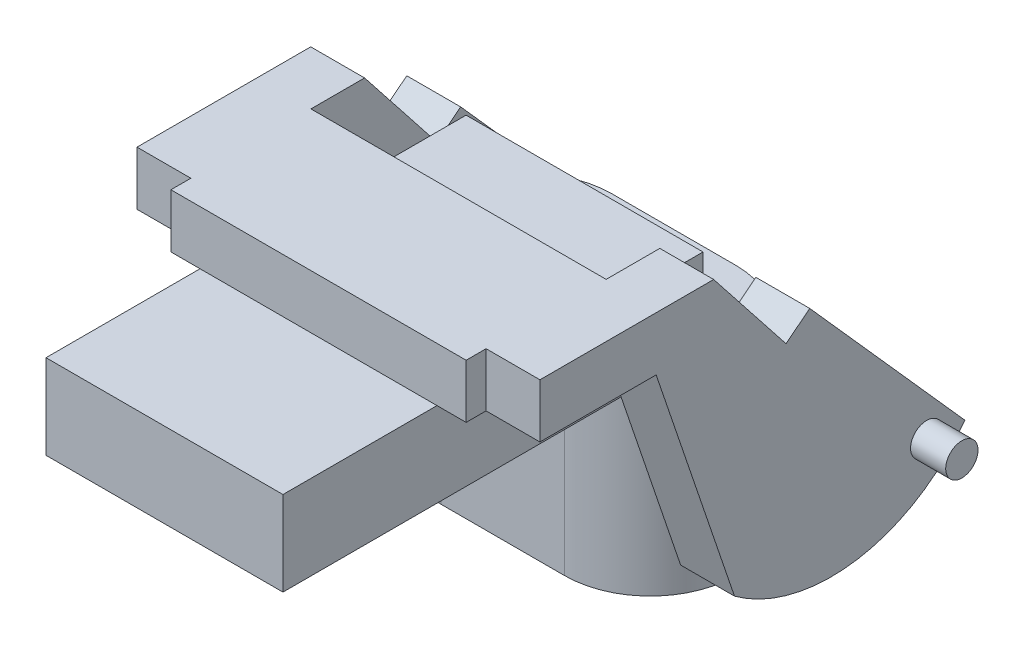
from build123d import *

# Parameters (mm, degrees)
SZKIC1_W                     = 44
SZKIC1_H                     = 78
DODANIE_WYCI_GNI_CIE1_DEPTH  = 15.7
SZKIC2_W                     = 54.82
SZKIC2_H                     = 26
DODANIE_WYCI_GNI_CIE2_DEPTH  = 10
DODANIE_WYCI_GNI_CIE3_DEPTH  = 1
SZKIC6_R                     = 10.4
SZKIC6_R_2                   = 4
DODANIE_WYCI_GNI_CIE4_DEPTH  = 33
SZKIC7_R                     = 10.5
DODANIE_WYCI_GNI_CIE5_DEPTH  = 33
DODANIE_WYCI_GNI_CIE6_DEPTH  = 33
DODANIE_WYCI_GNI_CIE22_DEPTH = 10
SZKIC15_R                    = 3
DODANIE_WYCI_GNI_CIE23_DEPTH = 6.525


with BuildPart() as part:
    # Szkic1 → Dodanie-wyciągnięcie1 (new body)
    with BuildSketch(Plane(origin=(0, 0, 0), x_dir=(1, 0, 0), z_dir=(0, 1, 0))):
        with Locations((-44.05199022, 33.7842123)):
            Rectangle(SZKIC1_W, SZKIC1_H)
    extrude(amount=DODANIE_WYCI_GNI_CIE1_DEPTH)

    # Szkic2 → Dodanie-wyciągnięcie2 (add)
    with BuildSketch(Plane(origin=(0, 15.7, 0), x_dir=(1, 0, 0), z_dir=(0, 1, 0))):
        with Locations((-44.05199022, 36.3842123)):
            Rectangle(SZKIC2_W, SZKIC2_H)
    extrude(amount=DODANIE_WYCI_GNI_CIE2_DEPTH)

    # Szkic3 → Dodanie-wyciągnięcie3 (add)
    with BuildSketch(Plane.XZ):
        with BuildLine():
            Line((-32.55199022, -89.3842123), (-55.55199022, -89.3842123))
            ThreePointArc((-55.55199022, -89.3842123), (-71.45199022, -73.4842123), (-55.55199022, -57.5842123))
            Line((-55.55199022, -57.5842123), (-32.55199022, -57.5842123))
            ThreePointArc((-32.55199022, -57.5842123), (-16.65199022, -73.4842123), (-32.55199022, -89.3842123))
        make_face()
    extrude(amount=DODANIE_WYCI_GNI_CIE3_DEPTH)

    # Szkic6 → Dodanie-wyciągnięcie4 (add)
    with BuildSketch(Plane(origin=(0, -1, 0), x_dir=(-1, 0, 0), z_dir=(0, -1, 0))):
        with Locations((32.55199022, 73.4842123)):
            Circle(SZKIC6_R)
        with Locations((32.55199022, 73.4842123)):
            Circle(SZKIC6_R_2, mode=Mode.SUBTRACT)
        with Locations((55.55199022, 73.4842123)):
            Circle(SZKIC6_R)
        with Locations((55.55199022, 73.4842123)):
            Circle(SZKIC6_R_2, mode=Mode.SUBTRACT)
    extrude(amount=DODANIE_WYCI_GNI_CIE4_DEPTH)

    # Szkic7 → Dodanie-wyciągnięcie5 (add)
    with BuildSketch(Plane(origin=(0, -1, 0), x_dir=(-1, 0, 0), z_dir=(0, -1, 0))):
        with BuildLine():
            Line((55.55199022, 57.9842123), (32.55199022, 57.9842123))
            ThreePointArc((32.55199022, 57.9842123), (17.05199022, 73.4842123), (32.55199022, 88.9842123))
            Line((32.55199022, 88.9842123), (55.55199022, 88.9842123))
            ThreePointArc((55.55199022, 88.9842123), (71.05199022, 73.4842123), (55.55199022, 57.9842123))
        make_face()
        with Locations((55.55199022, 73.4842123)):
            Circle(SZKIC7_R, mode=Mode.SUBTRACT)
        with Locations((32.55199022, 73.4842123)):
            Circle(SZKIC7_R, mode=Mode.SUBTRACT)
    extrude(amount=DODANIE_WYCI_GNI_CIE5_DEPTH)

    # Szkic8 → Dodanie-wyciągnięcie6 (add)
    with BuildSketch(Plane(origin=(0, -1, 0), x_dir=(-1, 0, 0), z_dir=(0, -1, 0))):
        with BuildLine():
            Line((32.55199022, 57.5842123), (55.55199022, 57.5842123))
            ThreePointArc((55.55199022, 57.5842123), (71.45199022, 73.4842123), (55.55199022, 89.3842123))
            Line((55.55199022, 89.3842123), (32.55199022, 89.3842123))
            ThreePointArc((32.55199022, 89.3842123), (16.65199022, 73.4842123), (32.55199022, 57.5842123))
        make_face()
        with BuildLine():
            Line((55.55199022, 57.7842123), (32.55199022, 57.7842123))
            ThreePointArc((32.55199022, 57.7842123), (16.85199022, 73.4842123), (32.55199022, 89.1842123))
            Line((32.55199022, 89.1842123), (55.55199022, 89.1842123))
            ThreePointArc((55.55199022, 89.1842123), (71.25199022, 73.4842123), (55.55199022, 57.7842123))
        make_face(mode=Mode.SUBTRACT)
    extrude(amount=DODANIE_WYCI_GNI_CIE6_DEPTH)

    # Szkic13 → Dodanie-wyciągnięcie22 (add)
    with BuildSketch(Plane(origin=(-16.64199022, 0, 0), x_dir=(0, 0, -1), z_dir=(1, 0, 0))):
        with BuildLine():
            Line((63.214194972, -27.158978782), (48.662895357, 15.7))
            Line((48.662895357, 15.7), (27.090339285, 15.7))
            Line((27.090339285, 15.7), (27.090339285, 25.7))
            Line((27.090339285, 25.7), (59.347416053, 25.7))
            Line((59.347416053, 25.7), (72.7842123, 8.659604885))
            Line((72.7842123, 8.659604885), (77.184359271, 12.129235601))
            Line((77.184359271, 12.129235601), (105.9842123, -20.239479664))
            ThreePointArc((105.9842123, -20.239479664), (86.046845732, -32.647229139), (63.214194972, -27.158978782))
        make_face()
    dodanie_wyci_gni_cie22 = extrude(amount=DODANIE_WYCI_GNI_CIE22_DEPTH)

    # Lustro2: Dodanie-wyciągnięcie22 across plane
    add(dodanie_wyci_gni_cie22.mirror(Plane(origin=(-44.05199022, 0, 0), x_dir=(0, 0, 1), z_dir=(1, 0, 0))))

    # Szkic15 → Dodanie-wyciągnięcie23 (add)
    with BuildSketch(Plane(origin=(-6.64199022, 0, 0), x_dir=(0, 0, -1), z_dir=(1, 0, 0))):
        with Locations((98.903450656, -19.74322341)):
            Circle(SZKIC15_R)
    dodanie_wyci_gni_cie23 = extrude(amount=DODANIE_WYCI_GNI_CIE23_DEPTH)

    # Lustro3: Dodanie-wyciągnięcie23 across plane
    add(dodanie_wyci_gni_cie23.mirror(Plane(origin=(-44.05199022, 0, 0), x_dir=(0, 0, 1), z_dir=(1, 0, 0))))


solid = part.part
